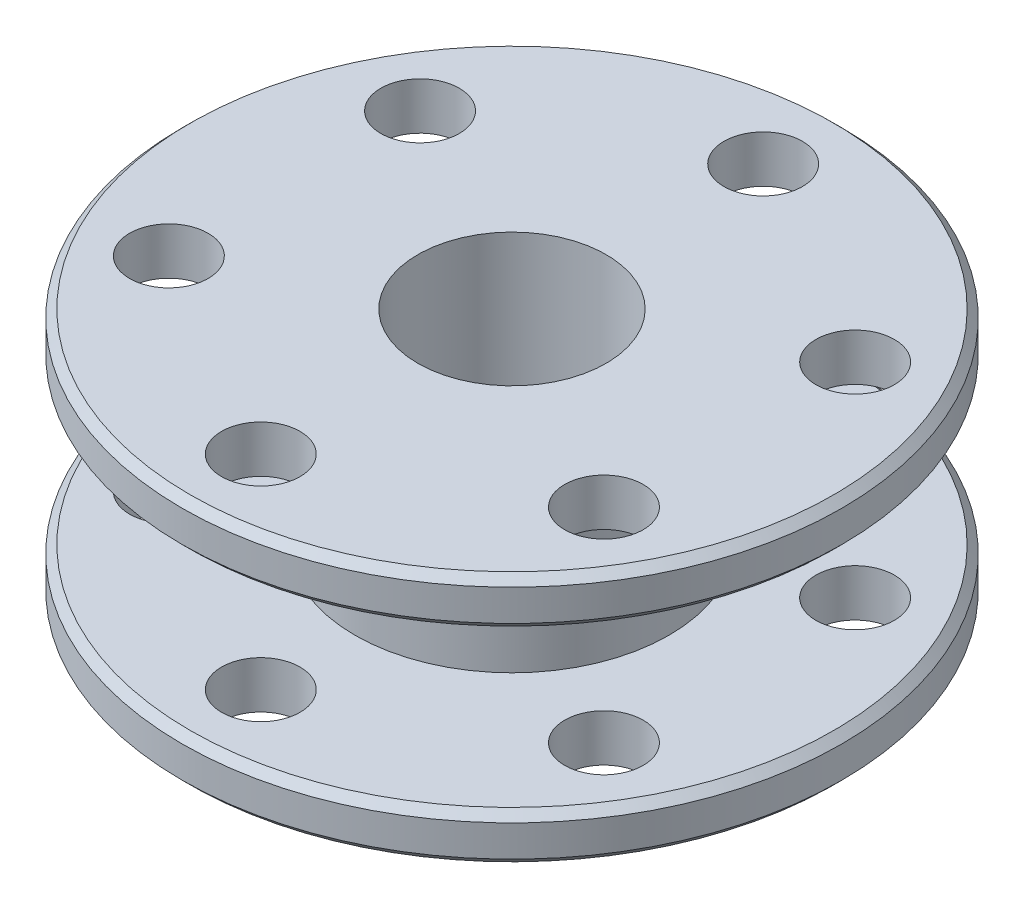
from build123d import *

# Parameters (mm, degrees)
CHAMFER1_SIZE           = 0.5
SKETCH2_R               = 2.5
CUT_EXTRUDE1_DEPTH      = 1
CUT_EXTRUDE1_DEPTH_BACK = 17


with BuildPart() as part:
    # Sketch1 → Revolve1 (revolve)
    with BuildSketch(Plane.XY):
        Polygon((-6, 8), (-6, -8), (-21, -8), (-21, -5), (-10, -5), (-10, 5), (-21, 5), (-21, 8), align=None)
    revolve(axis=Axis((0, 39.685139112, 0), (0, -1, 0)))

    # Chamfer1
    chamfer1_edges = [part.edges().sort_by_distance(p)[0] for p in [
        (21, -8, 0),
        (21, 8, 0),
        (21, 5, 0),
        (21, -5, 0),
    ]]
    chamfer(chamfer1_edges, length=CHAMFER1_SIZE)

    # Sketch2 → Cut-Extrude1 (cut, two sides)
    with BuildSketch(Plane.XZ.offset(8)) as cut_extrude1_sk:
        with Locations((0, 16)):
            Circle(SKETCH2_R)
        with Locations((13.856406461, 8)):
            Circle(SKETCH2_R)
        with Locations((13.856406461, -8)):
            Circle(SKETCH2_R)
        with Locations((0, -16)):
            Circle(SKETCH2_R)
        with Locations((-13.856406461, -8)):
            Circle(SKETCH2_R)
        with Locations((-13.856406461, 8)):
            Circle(SKETCH2_R)
    extrude(amount=CUT_EXTRUDE1_DEPTH, mode=Mode.SUBTRACT)
    extrude(cut_extrude1_sk.sketch, amount=-CUT_EXTRUDE1_DEPTH_BACK, mode=Mode.SUBTRACT)


solid = part.part
